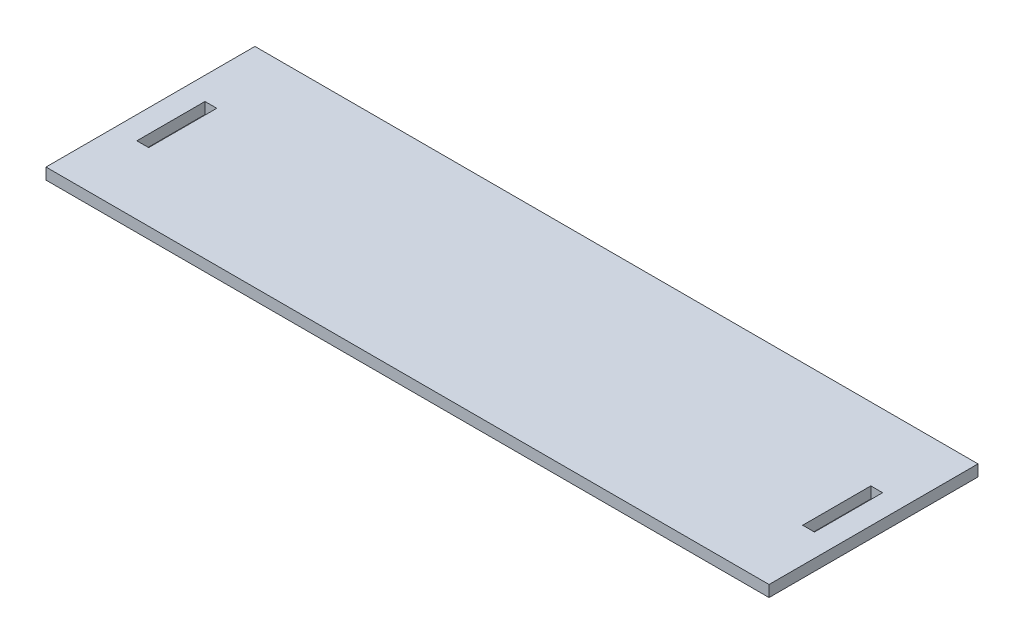
from build123d import *

# Parameters (mm, degrees)
SKETCH1_W           = 159.2
SKETCH1_H           = 45
SKETCH1_W_2         = 2.6
SKETCH1_H_2         = 15
BOSS_EXTRUDE1_DEPTH = 2.5
SKETCH3_W           = 159.2
SKETCH3_H           = 10
BOSS_EXTRUDE3_DEPTH = 2.5
SKETCH4_W           = 159.2
SKETCH4_H           = 9
CUT_EXTRUDE1_DEPTH  = 3.5


with BuildPart() as part:
    # Sketch1 → Boss-Extrude1 (new body)
    with BuildSketch(Plane(origin=(0, 0, 0), x_dir=(1, 0, 0), z_dir=(0, 1, 0))):
        Rectangle(SKETCH1_W, SKETCH1_H)
        with Locations((-73.3, 0)):
            Rectangle(SKETCH1_W_2, SKETCH1_H_2, mode=Mode.SUBTRACT)
        with Locations((73.3, 0)):
            Rectangle(SKETCH1_W_2, SKETCH1_H_2, mode=Mode.SUBTRACT)
    extrude(amount=BOSS_EXTRUDE1_DEPTH)

    # Sketch3 → Boss-Extrude3 (add)
    with BuildSketch(Plane(origin=(0, 2.5, 0), x_dir=(1, 0, 0), z_dir=(0, 1, 0))):
        with Locations((0, 27.5)):
            Rectangle(SKETCH3_W, SKETCH3_H)
    extrude(amount=-BOSS_EXTRUDE3_DEPTH)

    # Sketch4 → Cut-Extrude1 (cut, through all)
    with BuildSketch(Plane(origin=(0, 2.5, 0), x_dir=(1, 0, 0), z_dir=(0, 1, 0))):
        with Locations((0, 28)):
            Rectangle(SKETCH4_W, SKETCH4_H)
    extrude(amount=-CUT_EXTRUDE1_DEPTH, mode=Mode.SUBTRACT)


solid = part.part
